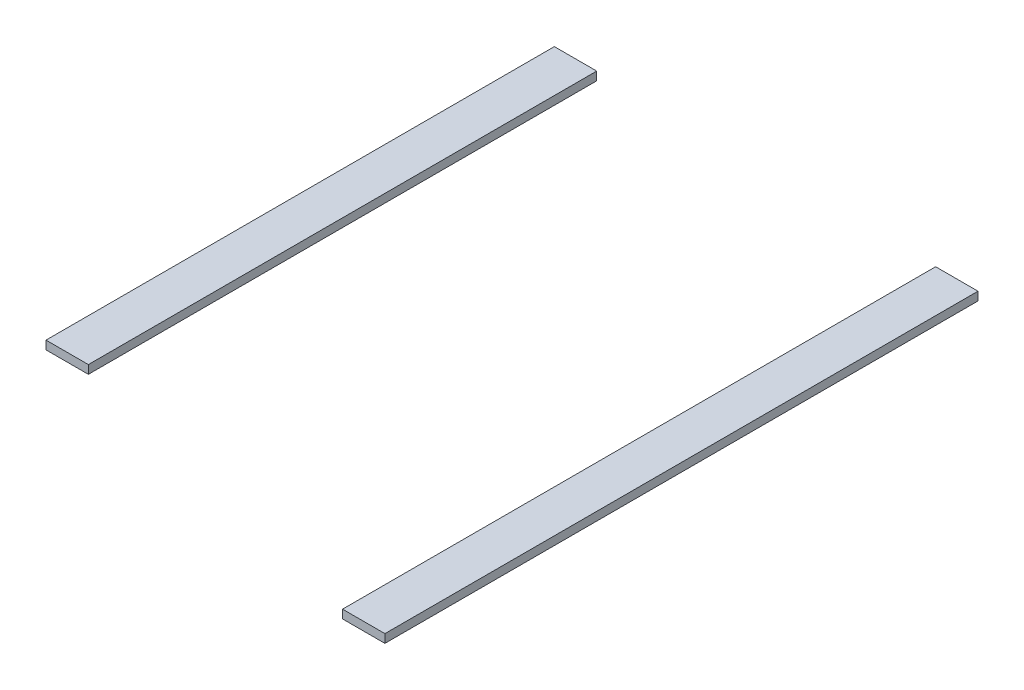
from build123d import *

# Parameters (mm, degrees)
SKETCH1_W             = 2.5
SKETCH1_H             = 35
BOSS_EXTRUDE1_DEPTH   = 0.5
SKETCH1_H_2           = 30
BOSS_EXTRUDE1_2_DEPTH = 0.5


with BuildPart() as part:
    # Sketch1 → Boss-Extrude1 (new body)
    with BuildSketch(Plane(origin=(0, 0, 0), x_dir=(1, 0, 0), z_dir=(0, 1, 0))):
        with Locations((22.5, -2.5)):
            Rectangle(SKETCH1_W, SKETCH1_H)
    extrude(amount=BOSS_EXTRUDE1_DEPTH)


with BuildPart() as body_2:
    # Sketch1 → Boss-Extrude1 2 (new body)
    with BuildSketch(Plane(origin=(0, 0, 0), x_dir=(1, 0, 0), z_dir=(0, 1, 0))):
        Rectangle(SKETCH1_W, SKETCH1_H_2)
    extrude(amount=BOSS_EXTRUDE1_2_DEPTH)


solid = Compound([part.part, body_2.part])
